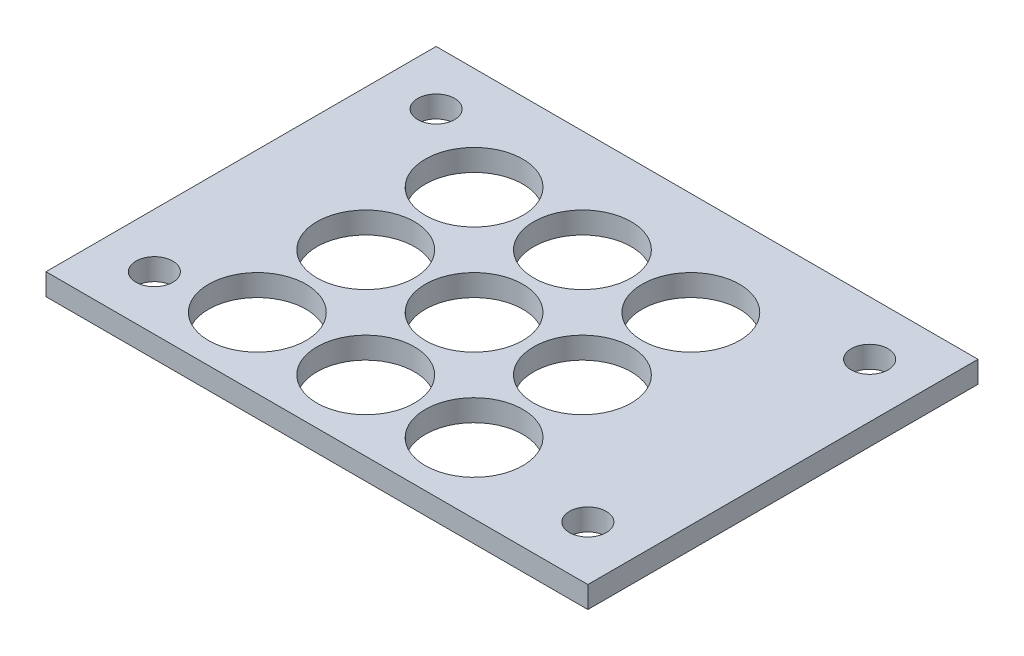
from build123d import *

# Parameters (mm, degrees)
SKETCH1_W           = 50
SKETCH1_H           = 36
SKETCH1_R           = 4.5
SKETCH1_R_2         = 1.7
BOSS_EXTRUDE1_DEPTH = 2


with BuildPart() as part:
    # Sketch1 → Boss-Extrude1 (new body)
    with BuildSketch(Plane(origin=(0, 0, 0), x_dir=(1, 0, 0), z_dir=(0, 1, 0))):
        with Locations((25, 18)):
            Rectangle(SKETCH1_W, SKETCH1_H)
        with Locations((13, 6.5)):
            Circle(SKETCH1_R, mode=Mode.SUBTRACT)
        with Locations((5, 5)):
            Circle(SKETCH1_R_2, mode=Mode.SUBTRACT)
        with Locations((5, 31)):
            Circle(SKETCH1_R_2, mode=Mode.SUBTRACT)
        with Locations((45, 31)):
            Circle(SKETCH1_R_2, mode=Mode.SUBTRACT)
        with Locations((45, 5)):
            Circle(SKETCH1_R_2, mode=Mode.SUBTRACT)
        with Locations((23, 6.5)):
            Circle(SKETCH1_R, mode=Mode.SUBTRACT)
        with Locations((33, 6.5)):
            Circle(SKETCH1_R, mode=Mode.SUBTRACT)
        with Locations((23, 16.5)):
            Circle(SKETCH1_R, mode=Mode.SUBTRACT)
        with Locations((33, 16.5)):
            Circle(SKETCH1_R, mode=Mode.SUBTRACT)
        with Locations((23, 26.5)):
            Circle(SKETCH1_R, mode=Mode.SUBTRACT)
        with Locations((33, 26.5)):
            Circle(SKETCH1_R, mode=Mode.SUBTRACT)
        with Locations((13, 16.5)):
            Circle(SKETCH1_R, mode=Mode.SUBTRACT)
        with Locations((13, 26.5)):
            Circle(SKETCH1_R, mode=Mode.SUBTRACT)
    extrude(amount=BOSS_EXTRUDE1_DEPTH)


solid = part.part
